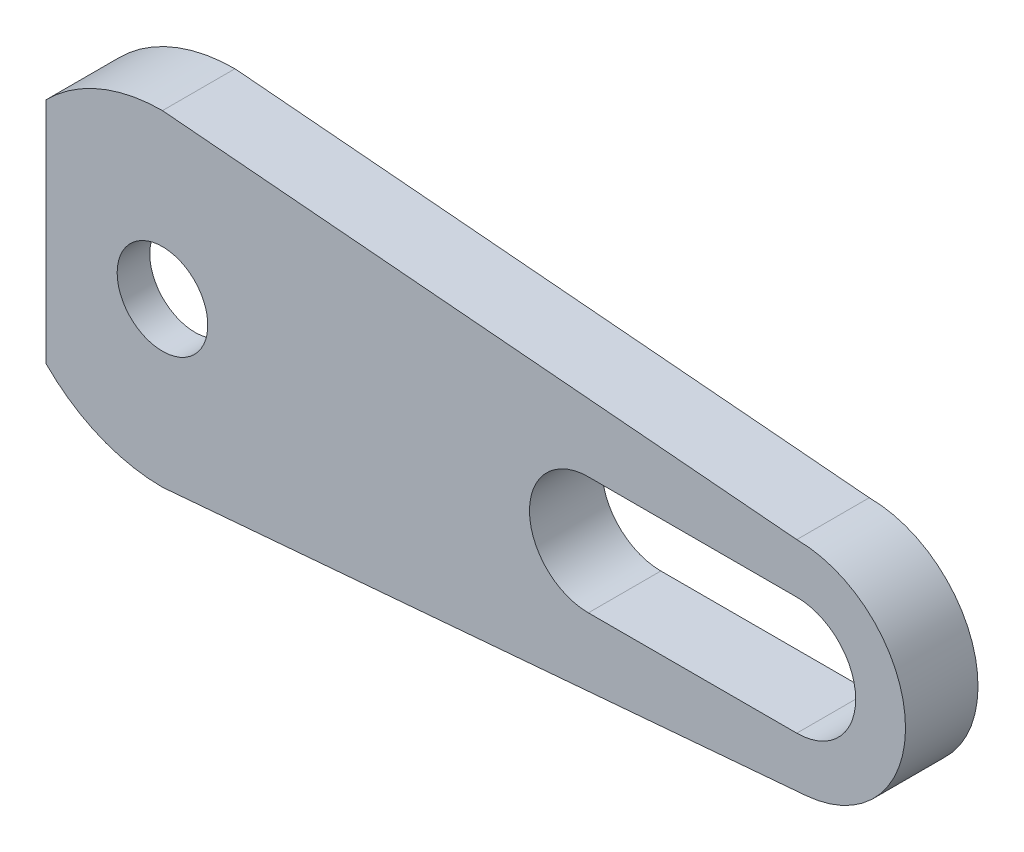
from build123d import *

# Parameters (mm, degrees)
MAIN_DEPTH          = 4
ESQUISSE2_R         = 2.5
BOSS_EXTRUDE1_DEPTH = 1.8


with BuildPart() as part:
    # Esquisse1 → Main (new body)
    with BuildSketch(Plane.XY):
        with BuildLine():
            Line((-4.375785644, 4.25), (-6.426543071, 6.300757427))
            ThreePointArc((-6.426543071, 6.300757427), (-3.48519606, 8.297795395), (0, 9))
            Line((0, 9), (35, 6))
            ThreePointArc((35, 6), (40.994596048, 0.254594236), (35.508729866, -5.978393925))
            Line((35.508729866, -5.978393925), (0, -9))
            ThreePointArc((0, -9), (-3.48519606, -8.297795395), (-6.426543071, -6.300757427))
            Line((-6.426543071, -6.300757427), (-4.375785644, -4.25))
            ThreePointArc((-4.375785644, -4.25), (0, -6.1), (4.375785644, -4.25))
            Line((4.375785644, -4.25), (17.31559729, -2.78215714))
            ThreePointArc((17.31559729, -2.78215714), (19.8, 0), (17.31559729, 2.78215714))
            Line((17.31559729, 2.78215714), (4.375785644, 4.25))
            ThreePointArc((4.375785644, 4.25), (0, 6.1), (-4.375785644, 4.25))
        make_face()
        with BuildLine():
            Line((23.5, 3.25), (35, 3.25))
            ThreePointArc((35, 3.25), (38.25, 0), (35, -3.25))
            Line((35, -3.25), (23.5, -3.25))
            ThreePointArc((23.5, -3.25), (20.25, 0), (23.5, 3.25))
        make_face(mode=Mode.SUBTRACT)
    extrude(amount=MAIN_DEPTH)

    # Esquisse2 → Boss-Extrude1 (add)
    with BuildSketch(Plane(origin=(0, 0, 4), x_dir=(-1, 0, 0), z_dir=(0, 0, -1))):
        with BuildLine():
            Line((0, -9), (-13.008239171, -7.893067292))
            ThreePointArc((-13.008239171, -7.893067292), (-20.250000727, -0.004029611), (-13.008239171, 7.885008071))
            Line((-13.008239171, 7.885008071), (0, 9))
            ThreePointArc((0, 9), (3.48519606, 8.297795395), (6.426543071, 6.300757427))
            Line((6.426543071, 6.300757427), (6.426543071, -6.300757427))
            ThreePointArc((6.426543071, -6.300757427), (3.48519606, -8.297795395), (0, -9))
        make_face()
        Circle(ESQUISSE2_R, mode=Mode.SUBTRACT)
    extrude(amount=BOSS_EXTRUDE1_DEPTH)


solid = part.part
